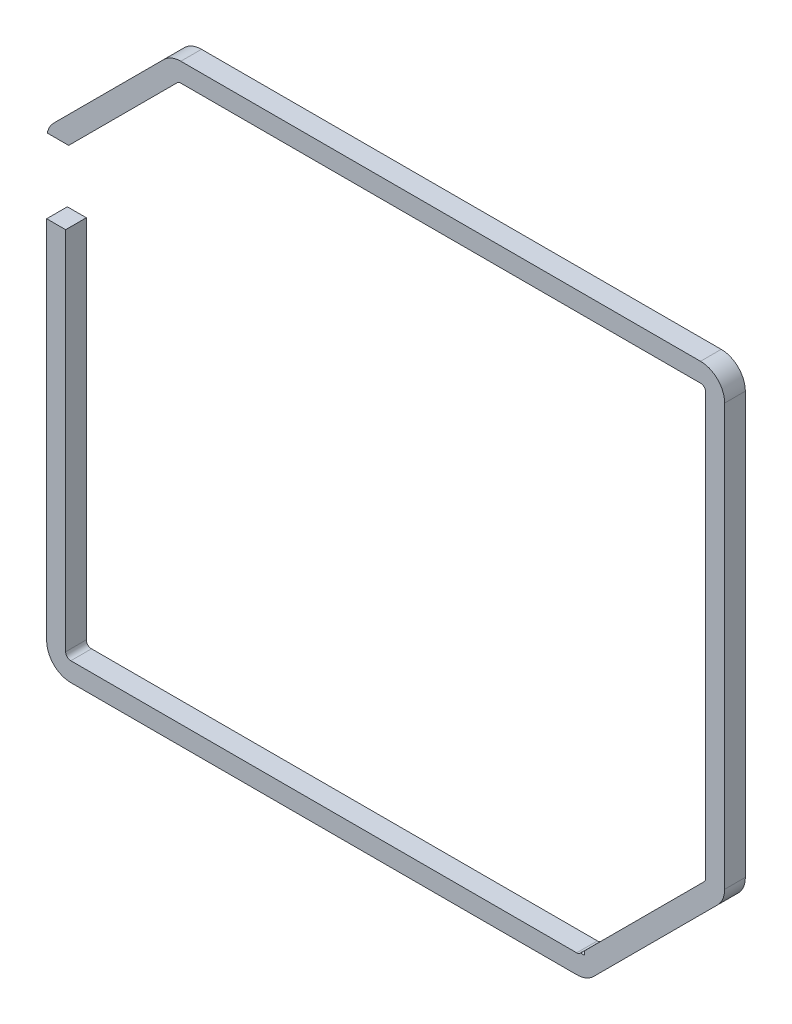
from build123d import *

# Parameters (mm, degrees)
BOSS_EXTRUDE1_DEPTH = 3
FILLET1_R           = 3.5
SKETCH2_W           = 72.4
SKETCH2_H           = 45
CUT_EXTRUDE1_DEPTH  = 104.986008674
SKETCH3_W           = 33
SKETCH3_H           = 18
SKETCH3_W_2         = 39
SKETCH3_H_2         = 18.5
SKETCH3_W_3         = 15
SKETCH3_H_3         = 30
CUT_EXTRUDE2_DEPTH  = 104.986008674
SKETCH4_W           = 39
SKETCH4_H           = 18.5
SKETCH4_W_2         = 15
SKETCH4_H_2         = 30
SKETCH4_W_3         = 72.4
SKETCH4_H_3         = 45
CUT_EXTRUDE3_DEPTH  = 104.986008674


with BuildPart() as part:
    # Sketch1 → Boss-Extrude1 (new body)
    with BuildSketch(Plane.XY):
        Polygon((60.3, -20), (80.3, 0), (80.3, 66), (0, 66), (-18, 48), (-18, -20), align=None)
    extrude(amount=BOSS_EXTRUDE1_DEPTH)

    # Fillet1
    fillet1_edges = [part.edges().sort_by_distance(p)[0] for p in [
        (80.3, 0, 1.5),
        (60.3, -20, 1.5),
        (-18, -20, 1.5),
        (-18, 48, 1.5),
        (80.3, 66, 1.5),
        (0, 66, 1.5),
    ]]
    fillet(fillet1_edges, radius=FILLET1_R)

    # Sketch2 → Cut-Extrude1 (cut, through all)
    with BuildSketch(Plane.XY.offset(3)):
        with Locations((39.2, 33)):
            Rectangle(SKETCH2_W, SKETCH2_H)
    extrude(amount=-CUT_EXTRUDE1_DEPTH, mode=Mode.SUBTRACT)

    # Sketch3 → Cut-Extrude2 (cut, through all)
    with BuildSketch(Plane.XY.offset(3)):
        with Locations((43.5, -8)):
            Rectangle(SKETCH3_W, SKETCH3_H)
        with Locations((4.5, -7.75)):
            Rectangle(SKETCH3_W_2, SKETCH3_H_2)
        with Locations((-7.5, 19.5)):
            Rectangle(SKETCH3_W_3, SKETCH3_H_3)
        with BuildLine():
            Line((-3, 47.3), (-17.918753974, 47.3))
            ThreePointArc((-17.918753974, 47.3), (-17.979629212, 46.927320889), (-18, 46.550252532))
            Line((-18, 46.550252532), (-18, 36.5))
            Line((-18, 36.5), (-3, 36.5))
            Line((-3, 36.5), (-3, 47.3))
        make_face()
        Polygon((63, -4.572077939), (67.242640687, -8.814718626), (71.485281374, -4.572077939), (67.242640687, -0.329437252), align=None)
    extrude(amount=-CUT_EXTRUDE2_DEPTH, mode=Mode.SUBTRACT)

    # Sketch4 → Cut-Extrude3 (cut, through all)
    with BuildSketch(Plane.XY.offset(3)):
        with BuildLine():
            Line((0.919417382, 63.030330086), (-14.810912703, 47.3))
            Line((-14.810912703, 47.3), (-3, 47.3))
            Line((-3, 47.3), (-3, 36.5))
            Line((-3, 36.5), (-15.249922187, 36.5))
            Line((-15.249922187, 36.5), (-15.25, 36.489656324))
            Line((-15.25, 36.489656324), (-15.25, -16.5))
            ThreePointArc((-15.25, -16.5), (-15.030330086, -17.030330086), (-14.5, -17.25))
            Line((-14.5, -17.25), (58.850252532, -17.25))
            ThreePointArc((58.850252532, -17.25), (59.137265106, -17.192909649), (59.380582618, -17.030330086))
            Line((59.380582618, -17.030330086), (59.410912703, -17))
            Line((59.410912703, -17), (27, -17))
            Line((27, -17), (27, 1))
            Line((27, 1), (60, 1))
            Line((60, 1), (60, -16.410912703))
            Line((60, -16.410912703), (77.330330086, 0.919417382))
            ThreePointArc((77.330330086, 0.919417382), (77.492909649, 1.162734894), (77.55, 1.449747468))
            Line((77.55, 1.449747468), (77.55, 62.5))
            ThreePointArc((77.55, 62.5), (77.330330086, 63.030330086), (76.8, 63.25))
            Line((76.8, 63.25), (1.449747468, 63.25))
            ThreePointArc((1.449747468, 63.25), (1.162734894, 63.192909649), (0.919417382, 63.030330086))
        make_face()
        with Locations((4.5, -7.75)):
            Rectangle(SKETCH4_W, SKETCH4_H, mode=Mode.SUBTRACT)
        with Locations((-7.5, 19.5)):
            Rectangle(SKETCH4_W_2, SKETCH4_H_2, mode=Mode.SUBTRACT)
        Polygon((67.242640687, -8.814718626), (63, -4.572077939), (67.242640687, -0.329437252), (71.485281374, -4.572077939), align=None, mode=Mode.SUBTRACT)
        with Locations((39.2, 33)):
            Rectangle(SKETCH4_W_3, SKETCH4_H_3, mode=Mode.SUBTRACT)
    extrude(amount=-CUT_EXTRUDE3_DEPTH, mode=Mode.SUBTRACT)


solid = part.part
